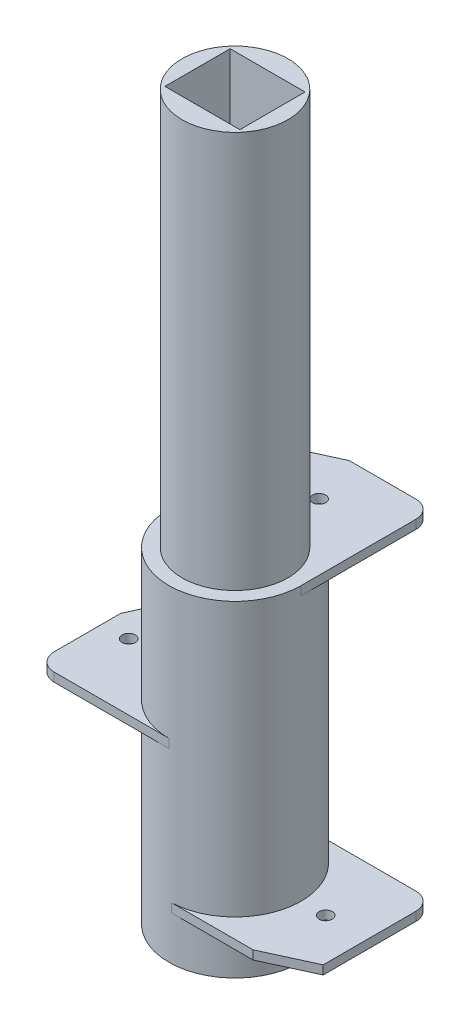
from build123d import *

# Parameters (mm, degrees)
SKETCH1_R            = 7.5
BOSS_EXTRUDE6_DEPTH  = 5
BOSS_EXTRUDE7_DEPTH  = 1
SKETCH22_R           = 7.5
BOSS_EXTRUDE12_DEPTH = 8
SKETCH30_R           = 4.2
CUT_EXTRUDE8_DEPTH   = 2
SKETCH31_R           = 2.1
CUT_EXTRUDE9_DEPTH   = 9
SKETCH33_R           = 7.5
BOSS_EXTRUDE19_DEPTH = 8
BOSS_EXTRUDE20_DEPTH = 1
SKETCH35_R           = 7.5
BOSS_EXTRUDE21_DEPTH = 15
BOSS_EXTRUDE22_DEPTH = 1
SKETCH37_R           = 7.5
BOSS_EXTRUDE23_DEPTH = 1
SKETCH38_R           = 6
BOSS_EXTRUDE24_DEPTH = 45
CUT_EXTRUDE11_DEPTH  = 1
CUT_EXTRUDE12_DEPTH  = 1
CUT_EXTRUDE13_DEPTH  = 1
SKETCH44_W           = 8.5
SKETCH44_H           = 7.4
CUT_EXTRUDE19_DEPTH  = 20
FILLET3_R            = 2
FILLET4_R            = 2
FILLET5_R            = 2
SKETCH51_R           = 0.7
BOSS_EXTRUDE25_DEPTH = 1.2
SKETCH53_R           = 0.7
BOSS_EXTRUDE27_DEPTH = 1.2
SKETCH52_R           = 0.7
BOSS_EXTRUDE28_DEPTH = 1.2
SKETCH59_R           = 0.75
CUT_EXTRUDE23_DEPTH  = 2
SKETCH60_R           = 0.75
CUT_EXTRUDE25_DEPTH  = 2
SKETCH58_R           = 0.75
CUT_EXTRUDE29_DEPTH  = 10


with BuildPart() as part:
    # Sketch1 → Boss-Extrude6 (new body)
    with BuildSketch(Plane(origin=(0, 0, 0), x_dir=(1, 0, 0), z_dir=(0, 1, 0))):
        Circle(SKETCH1_R)
    extrude(amount=BOSS_EXTRUDE6_DEPTH)

    # Sketch22 → Boss-Extrude12 (add)
    with BuildSketch(Plane(origin=(0, 5, 0), x_dir=(1, 0, 0), z_dir=(0, 1, 0))):
        Circle(SKETCH22_R)
    extrude(amount=BOSS_EXTRUDE12_DEPTH)

    # Sketch30 → Cut-Extrude8 (cut)
    with BuildSketch(Plane.XZ):
        Circle(SKETCH30_R)
    extrude(amount=-CUT_EXTRUDE8_DEPTH, mode=Mode.SUBTRACT)

    # Sketch31 → Cut-Extrude9 (cut)
    with BuildSketch(Plane.XZ.offset(-2)):
        Circle(SKETCH31_R)
    extrude(amount=-CUT_EXTRUDE9_DEPTH, mode=Mode.SUBTRACT)

    # Sketch33 → Boss-Extrude19 (add)
    with BuildSketch(Plane(origin=(0, 13, 0), x_dir=(1, 0, 0), z_dir=(0, 1, 0))):
        Circle(SKETCH33_R)
    extrude(amount=BOSS_EXTRUDE19_DEPTH)



with BuildPart() as body_2:
    # Sketch16 → Boss-Extrude7 (new body)
    with BuildSketch(Plane(origin=(0, 5, 0), x_dir=(1, 0, 0), z_dir=(0, 1, 0))):
        with BuildLine():
            Line((15, 7.5), (0, 7.5))
            ThreePointArc((0, 7.5), (7.501258216, 0.134044682), (0.2730459, -7.500031508))
            Line((0.2730459, -7.500031508), (15, -7.500031508))
            Line((15, -7.500031508), (15, 7.5))
        make_face()
    extrude(amount=BOSS_EXTRUDE7_DEPTH)

    # Sketch41 → Cut-Extrude12 (cut)
    with BuildSketch(Plane(origin=(0, 6, 0), x_dir=(1, 0, 0), z_dir=(0, 1, 0))):
        Polygon((15, -5.000031508), (9.545643943, -7.500031508), (15, -7.500031508), align=None)
    extrude(amount=-CUT_EXTRUDE12_DEPTH, mode=Mode.SUBTRACT)

    # Fillet3
    fillet3_edges = [body_2.edges().sort_by_distance(p)[0] for p in [
        (15, 5.5, -7.5),
    ]]
    fillet(fillet3_edges, radius=FILLET3_R)

    # Sketch51 → Boss-Extrude25 (add)
    with BuildSketch(Plane.XZ.offset(-5)):
        with Locations((11, -4)):
            Circle(SKETCH51_R)
    extrude(amount=BOSS_EXTRUDE25_DEPTH)

    # Sketch60 → Cut-Extrude25 (cut)
    with BuildSketch(Plane.XZ.offset(-5)):
        with Locations((10.286249768, 0)):
            Circle(SKETCH60_R)
    extrude(amount=-CUT_EXTRUDE25_DEPTH, mode=Mode.SUBTRACT)


with BuildPart() as body_3:
    # Sketch34 → Boss-Extrude20 (new body)
    with BuildSketch(Plane(origin=(0, 21, 0), x_dir=(1, 0, 0), z_dir=(0, 1, 0))):
        with BuildLine():
            Line((0, 7.5), (-15, 7.5))
            Line((-15, 7.5), (-15, -7.5))
            Line((-15, -7.5), (0, -7.5))
            ThreePointArc((0, -7.5), (-7.5, 0), (0, 7.5))
        make_face()
    extrude(amount=BOSS_EXTRUDE20_DEPTH)


with BuildPart() as part_1:
    add(part.part)

    add(body_3.part)  # Boss-Extrude21 merges body 3
    # Sketch35 → Boss-Extrude21 (add)
    with BuildSketch(Plane(origin=(0, 21, 0), x_dir=(1, 0, 0), z_dir=(0, 1, 0))):
        Circle(SKETCH35_R)
    extrude(amount=BOSS_EXTRUDE21_DEPTH)



with BuildPart() as body_3_2:
    # Sketch36 → Boss-Extrude22 (new body)
    with BuildSketch(Plane(origin=(0, 36, 0), x_dir=(1, 0, 0), z_dir=(0, 1, 0))):
        with BuildLine():
            Line((7.5, 0), (7.5, 15))
            Line((7.5, 15), (-7.5, 15))
            Line((-7.5, 15), (-7.5, 0))
            ThreePointArc((-7.5, 0), (0, 7.5), (7.5, 0))
        make_face()
    extrude(amount=BOSS_EXTRUDE22_DEPTH)


with BuildPart() as part_2:
    add(part_1.part)

    add(body_3_2.part)  # Boss-Extrude23 merges body 3 2
    # Sketch37 → Boss-Extrude23 (add)
    with BuildSketch(Plane(origin=(0, 36, 0), x_dir=(1, 0, 0), z_dir=(0, 1, 0))):
        Circle(SKETCH37_R)
    extrude(amount=BOSS_EXTRUDE23_DEPTH)

    # Sketch38 → Boss-Extrude24 (add)
    with BuildSketch(Plane(origin=(0, 37, 0), x_dir=(1, 0, 0), z_dir=(0, 1, 0))):
        Circle(SKETCH38_R)
    extrude(amount=BOSS_EXTRUDE24_DEPTH)

    # Sketch40 → Cut-Extrude11 (cut)
    with BuildSketch(Plane(origin=(0, 37, 0), x_dir=(1, 0, 0), z_dir=(0, 1, 0))):
        Polygon((-7.5, 15), (-7.5, 12.5), (-2.045643943, 15), align=None)
    extrude(amount=-CUT_EXTRUDE11_DEPTH, mode=Mode.SUBTRACT)

    # Sketch42 → Cut-Extrude13 (cut)
    with BuildSketch(Plane(origin=(0, 22, 0), x_dir=(1, 0, 0), z_dir=(0, 1, 0))):
        Polygon((-15, 2.045643943), (-12.5, 7.5), (-15, 7.5), align=None)
    extrude(amount=-CUT_EXTRUDE13_DEPTH, mode=Mode.SUBTRACT)

    # Sketch44 → Cut-Extrude19 (cut)
    with BuildSketch(Plane(origin=(0, 82, 0), x_dir=(1, 0, 0), z_dir=(0, 1, 0))):
        Rectangle(SKETCH44_W, SKETCH44_H)
    extrude(amount=-CUT_EXTRUDE19_DEPTH, mode=Mode.SUBTRACT)

    # Fillet4
    fillet4_edges = [part_2.edges().sort_by_distance(p)[0] for p in [
        (-15, 21.5, 7.5),
    ]]
    fillet(fillet4_edges, radius=FILLET4_R)

    # Fillet5
    fillet5_edges = [part_2.edges().sort_by_distance(p)[0] for p in [
        (7.5, 36.5, -15),
    ]]
    fillet(fillet5_edges, radius=FILLET5_R)

    # Sketch53 → Boss-Extrude27 (add)
    with BuildSketch(Plane.XZ.offset(-36)):
        with Locations((-3.5, -11.5)):
            Circle(SKETCH53_R)
    extrude(amount=BOSS_EXTRUDE27_DEPTH)

    # Sketch52 → Boss-Extrude28 (add)
    with BuildSketch(Plane.XZ.offset(-21)):
        with Locations((-11, 4)):
            Circle(SKETCH52_R)
    extrude(amount=BOSS_EXTRUDE28_DEPTH)

    # Sketch59 → Cut-Extrude23 (cut)
    with BuildSketch(Plane.XZ.offset(-36)):
        with Locations((0, -9.535999741)):
            Circle(SKETCH59_R)
    extrude(amount=-CUT_EXTRUDE23_DEPTH, mode=Mode.SUBTRACT)

    # Sketch58 → Cut-Extrude29 (cut)
    with BuildSketch(Plane.XZ.offset(-21)):
        with Locations((-12.054198947, 0)):
            Circle(SKETCH58_R)
    extrude(amount=-CUT_EXTRUDE29_DEPTH, mode=Mode.SUBTRACT)


solid = Compound([body_2.part, part_2.part])
